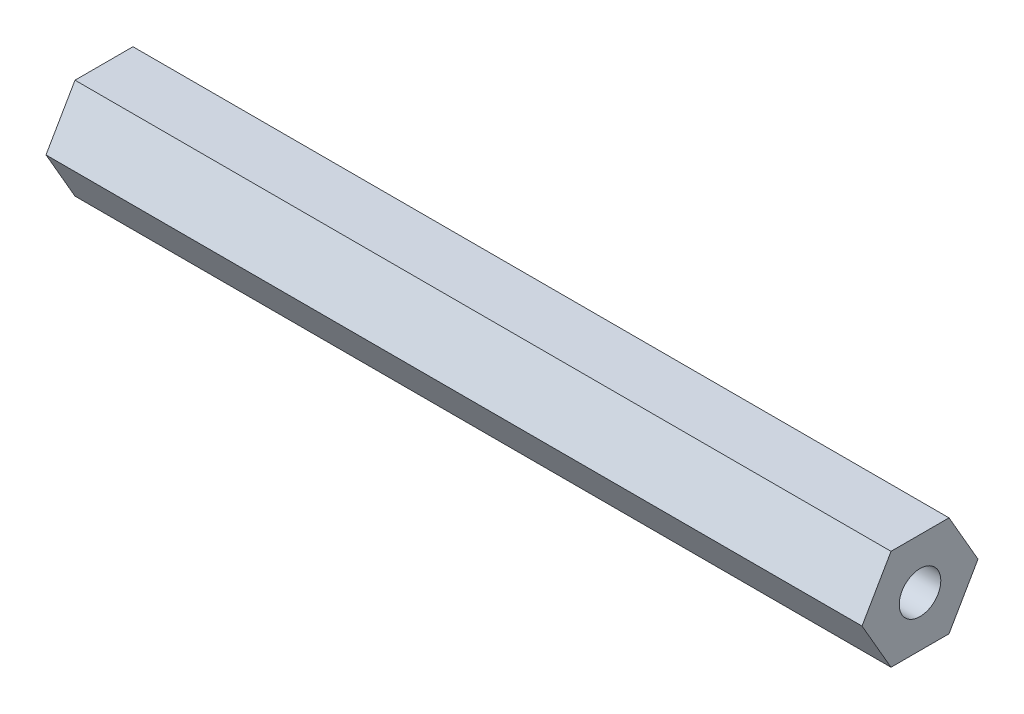
from build123d import *

# Parameters (mm, degrees)
SKETCH1_R           = 2.6289
BOSS_EXTRUDE1_DEPTH = 103.1875


with BuildPart() as part:
    # Sketch1 → Boss-Extrude1 (new body)
    with BuildSketch(Plane(origin=(0, 0, 0), x_dir=(0, 0, -1), z_dir=(1, 0, 0))):
        Polygon((3.666174209, 6.35), (-3.666174209, 6.35), (-7.332348419, 0), (-3.666174209, -6.35), (3.666174209, -6.35), (7.332348419, 0), align=None)
        Circle(SKETCH1_R, mode=Mode.SUBTRACT)
    extrude(amount=BOSS_EXTRUDE1_DEPTH)


solid = part.part
